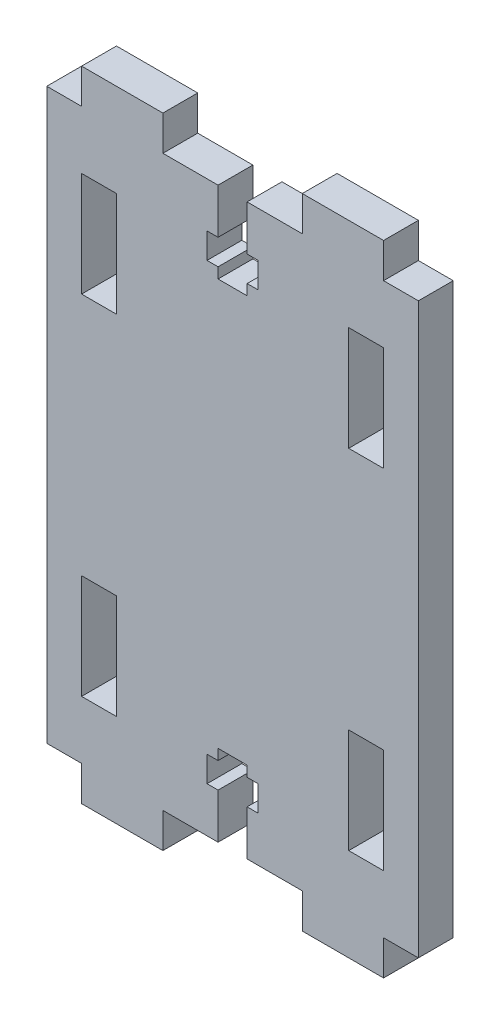
from build123d import *

# Parameters (mm, degrees)
SKETCH_1_W          = 32
SKETCH_1_H          = 55
EXTRUDE_1_DEPTH     = 3
SKETCH_2_W          = 3
SKETCH_2_H          = 3
SKETCH_2_W_2        = 12
CUT_EXTRUDE_1_DEPTH = 4
SKETCH_3_W          = 3
SKETCH_3_H          = 9
CUT_EXTRUDE_2_DEPTH = 4
CUT_EXTRUDE_3_DEPTH = 10


with BuildPart() as part:
    # 스케치1 → 보스-돌출1 (new body)
    with BuildSketch(Plane.XY):
        with Locations((16, 27.5)):
            Rectangle(SKETCH_1_W, SKETCH_1_H)
    extrude(amount=EXTRUDE_1_DEPTH)

    # 스케치2 → 컷-돌출1 (cut, through all)
    with BuildSketch(Plane.XY.offset(3)):
        with Locations((1.5, 53.5)):
            Rectangle(SKETCH_2_W, SKETCH_2_H)
        with Locations((16, 53.5)):
            Rectangle(SKETCH_2_W_2, SKETCH_2_H)
        with Locations((30.5, 53.5)):
            Rectangle(SKETCH_2_W, SKETCH_2_H)
        with Locations((1.5, 1.5)):
            Rectangle(SKETCH_2_W, SKETCH_2_H)
        with Locations((16, 1.5)):
            Rectangle(SKETCH_2_W_2, SKETCH_2_H)
        with Locations((30.5, 1.5)):
            Rectangle(SKETCH_2_W, SKETCH_2_H)
    extrude(amount=-CUT_EXTRUDE_1_DEPTH, mode=Mode.SUBTRACT)

    # 스케치3 → 컷-돌출2 (cut, through all)
    with BuildSketch(Plane.XY.offset(3)):
        with Locations((4.5, 42.5)):
            Rectangle(SKETCH_3_W, SKETCH_3_H)
        with Locations((27.5, 42.5)):
            Rectangle(SKETCH_3_W, SKETCH_3_H)
        with Locations((27.5, 12.5)):
            Rectangle(SKETCH_3_W, SKETCH_3_H)
        with Locations((4.5, 12.5)):
            Rectangle(SKETCH_3_W, SKETCH_3_H)
    extrude(amount=-CUT_EXTRUDE_2_DEPTH, mode=Mode.SUBTRACT)

    # 스케치5 → 컷-돌출3 (cut)
    with BuildSketch(Plane.XY.offset(3)):
        Polygon((14.75, 10), (17.25, 10), (17.25, 9.08840284), (18.2, 9.08840284), (18.2, 6.88840284), (17.25, 6.88840284), (17.25, 3), (14.75, 3), (14.75, 6.88840284), (13.8, 6.88840284), (13.8, 9.08840284), (14.75, 9.08840284), align=None)
        Polygon((14.75, 45), (14.75, 45.91159716), (13.8, 45.91159716), (13.8, 48.11159716), (14.75, 48.11159716), (14.75, 52), (17.25, 52), (17.25, 48.11159716), (18.2, 48.11159716), (18.2, 45.91159716), (17.25, 45.91159716), (17.25, 45), align=None)
    extrude(amount=-CUT_EXTRUDE_3_DEPTH, mode=Mode.SUBTRACT)


solid = part.part
